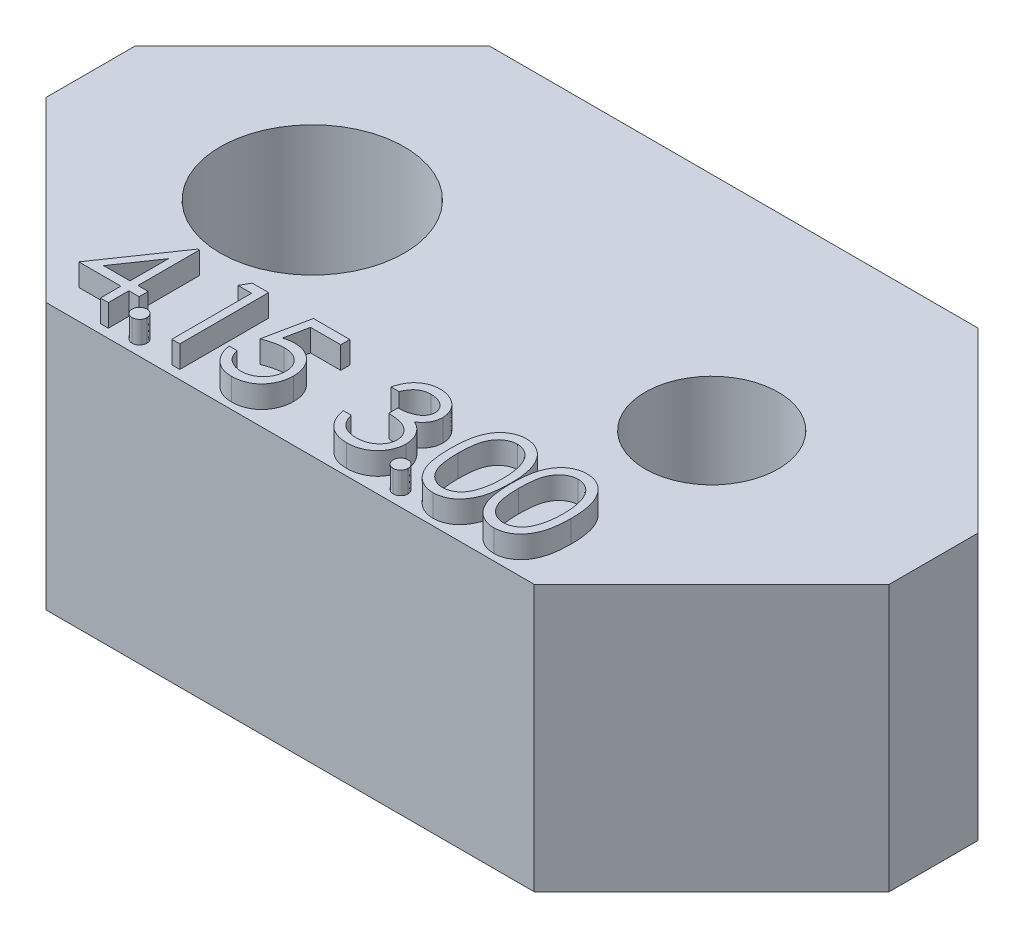
from build123d import *

# Parameters (mm, degrees)
SKETCH_1_R      = 2.075
SKETCH_1_R_2    = 1.5
EXTRUDE_1_DEPTH = 6
SKETCH_1_3_R    = 2.075
SKETCH_1_3_R_2  = 1.5
EXTRUDE_2_DEPTH = 2
EXTRUDE_3_DEPTH = 0.5


with BuildPart() as part:
    # Эскиз1 → Бобышка-Вытянуть1 (new body)
    with BuildSketch(Plane(origin=(0, 0, 0), x_dir=(1, 0, 0), z_dir=(0, 1, 0))):
        Polygon((9.5, 1), (5.5, 5), (-5.5, 5), (-9.5, 1), (-9.5, -1), (-5.5, -5), (5.5, -5), (9.5, -1), align=None)
        with Locations((-4.5, 0)):
            Circle(SKETCH_1_R, mode=Mode.SUBTRACT)
        with Locations((4.5, 0)):
            Circle(SKETCH_1_R_2, mode=Mode.SUBTRACT)
    extrude(amount=EXTRUDE_1_DEPTH)

    # Эскиз1<3> → Бобышка-Вытянуть2 (add)
    with BuildSketch(Plane(origin=(0, 0, 0), x_dir=(1, 0, 0), z_dir=(0, 1, 0))):
        with Locations((-4.5, 0)):
            Circle(SKETCH_1_3_R)
        with Locations((4.5, 0)):
            Circle(SKETCH_1_3_R_2)
    extrude(amount=EXTRUDE_2_DEPTH)

    # Эскиз3 → Бобышка-Вытянуть3 (add)
    # profile 1 of 8: a face of its own
    with BuildSketch(Plane(origin=(0, 6, 0), x_dir=(1, 0, 0), z_dir=(0, 1, 0))):
        Polygon((-4.331330128, -2.748717949), (-4.294871795, -2.748717949), (-4.294871795, -4.133333333), (-4.064102564, -4.133333333), (-4.064102564, -4.338461538), (-4.294871795, -4.338461538), (-4.294871795, -4.8), (-4.474358974, -4.8), (-4.474358974, -4.338461538), (-5.423076923, -4.338461538), align=None)
        Polygon((-4.474358974, -4.133333333), (-4.474358974, -3.26474359), (-5.070512821, -4.133333333), align=None, mode=Mode.SUBTRACT)
    # profile 2 of 8: a face of its own
    with BuildSketch(Plane(origin=(0, 6, 0), x_dir=(1, 0, 0), z_dir=(0, 1, 0))):
        with BuildLine():
            add(Edge.make_bspline(
                [(-3.733333333, -4.492307692), (-3.722196069, -4.492969502), (-3.700362765, -4.494266902), (-3.668797549, -4.503167858), (-3.640229172, -4.518972807), (-3.614782175, -4.540037252), (-3.593807045, -4.565577631), (-3.577438844, -4.59391815), (-3.568615424, -4.625747632), (-3.567327474, -4.647707446), (-3.566666667, -4.658974359)],
                knots=[0, 0, 0, 0, 1.020151414, 1.999887582, 2.974338812, 3.990962822, 5.007586832, 5.987933904, 6.967670073, 8, 8, 8, 8], degree=3))
            add(Edge.make_bspline(
                [(-3.566666667, -4.658974359), (-3.567349867, -4.669970547), (-3.568697128, -4.69165487), (-3.577418619, -4.723244277), (-3.59393179, -4.751602508), (-3.6146375, -4.777489444), (-3.640235462, -4.798598513), (-3.668865089, -4.814268996), (-3.700288665, -4.82380727), (-3.722183707, -4.825022297), (-3.733333333, -4.825641026)],
                knots=[0, 0, 0, 0, 1.009421747, 1.99056486, 2.972319754, 3.999869655, 5.017953583, 5.993804169, 6.978383603, 8, 8, 8, 8], degree=3))
            add(Edge.make_bspline(
                [(-3.733333333, -4.825641026), (-3.744490994, -4.825044684), (-3.766273669, -4.82388047), (-3.797579952, -4.814073152), (-3.826383934, -4.798745461), (-3.851976912, -4.777450084), (-3.872856039, -4.751735716), (-3.888641972, -4.723048975), (-3.898122057, -4.691745297), (-3.899368841, -4.669988358), (-3.9, -4.658974359)],
                knots=[0, 0, 0, 0, 1.022052826, 1.995314843, 2.982371812, 4.00089066, 5.028879526, 6.005146991, 6.990147033, 8, 8, 8, 8], degree=3))
            add(Edge.make_bspline(
                [(-3.9, -4.658974359), (-3.899393086, -4.647688999), (-3.898208161, -4.625655719), (-3.88862207, -4.594113372), (-3.87297852, -4.565445692), (-3.85183258, -4.540076218), (-3.826390125, -4.518826331), (-3.797649437, -4.503360735), (-3.766198271, -4.494194785), (-3.744478306, -4.492947633), (-3.733333333, -4.492307692)],
                knots=[0, 0, 0, 0, 1.032775665, 2.016367738, 2.991239715, 4.008302682, 5.025365648, 6.011011707, 6.979408107, 8, 8, 8, 8], degree=3))
        make_face()
    # profile 3 of 8: a face of its own
    with BuildSketch(Plane(origin=(0, 6, 0), x_dir=(1, 0, 0), z_dir=(0, 1, 0))):
        Polygon((-3.054407051, -2.8), (-2.684615385, -2.8), (-2.684615385, -4.8), (-2.864102564, -4.8), (-2.864102564, -3.005128205), (-3.171794872, -3.005128205), align=None)
    # profile 4 of 8: a face of its own
    with BuildSketch(Plane(origin=(0, 6, 0), x_dir=(1, 0, 0), z_dir=(0, 1, 0))):
        with BuildLine():
            Line((-0.853846154, -2.8), (-0.853846154, -3.005128205))
            Line((-0.853846154, -3.005128205), (-1.534134615, -3.005128205))
            Line((-1.534134615, -3.005128205), (-1.641907051, -3.531169872))
            add(Edge.make_bspline(
                [(-1.641907051, -3.531169872), (-1.620732266, -3.525324002), (-1.579709468, -3.513998554), (-1.519160976, -3.501423828), (-1.461679717, -3.493843575), (-1.424379506, -3.49280854), (-1.406330128, -3.492307692)],
                knots=[0, 0, 0, 0, 1.100273476, 2.13160584, 3.095893838, 4, 4, 4, 4], degree=3))
            add(Edge.make_bspline(
                [(-1.406330128, -3.492307692), (-1.383996563, -3.492791084), (-1.340083193, -3.493741553), (-1.275832366, -3.502868324), (-1.214499284, -3.51723399), (-1.156212215, -3.537302859), (-1.100863329, -3.562965564), (-1.048961866, -3.595022673), (-0.999728772, -3.632470291), (-0.95404729, -3.675524583), (-0.912604828, -3.722908364), (-0.87616712, -3.773855719), (-0.845217068, -3.827871526), (-0.820325208, -3.885471874), (-0.800448446, -3.946019962), (-0.787218735, -4.010152866), (-0.778409187, -4.077266077), (-0.777424966, -4.123154403), (-0.776923077, -4.146554487)],
                knots=[0, 0, 0, 0, 1.052922333, 2.070308379, 3.05430497, 4.020497103, 4.973039431, 5.925935799, 6.892292201, 7.88610001, 8.88166317, 9.857072816, 10.836096531, 11.812156883, 12.81219415, 13.836441305, 14.89672472, 16, 16, 16, 16], degree=3))
            add(Edge.make_bspline(
                [(-0.776923077, -4.146554487), (-0.77730312, -4.162852899), (-0.77805807, -4.195229463), (-0.781897263, -4.243311864), (-0.789289101, -4.29037634), (-0.799213514, -4.336429135), (-0.812094896, -4.381383062), (-0.827688641, -4.425366792), (-0.846772086, -4.468106567), (-0.8677043, -4.510006793), (-0.891273716, -4.550120226), (-0.917432863, -4.587633932), (-0.945070287, -4.623110665), (-0.974808221, -4.656169941), (-1.006923076, -4.686594522), (-1.041025914, -4.714564969), (-1.07684461, -4.740554301), (-1.11493332, -4.763507555), (-1.15444331, -4.784629244), (-1.195945149, -4.80195698), (-1.238494121, -4.81744871), (-1.282702621, -4.829797012), (-1.328470514, -4.839472757), (-1.375873243, -4.846044529), (-1.424662197, -4.850831064), (-1.457733633, -4.851130697), (-1.474439103, -4.851282051)],
                knots=[0, 0, 0, 0, 1.056347294, 2.098418968, 3.122841568, 4.141288669, 5.149314143, 6.15115421, 7.162517403, 8.180376062, 9.185164535, 10.17417709, 11.141909838, 12.097768115, 13.052685741, 14.0056014, 14.954263652, 15.917497458, 16.885230207, 17.854509472, 18.828990115, 19.81800267, 20.826176721, 21.857883937, 22.917946725, 24, 24, 24, 24], degree=3))
            add(Edge.make_bspline(
                [(-1.474439103, -4.851282051), (-1.494367206, -4.850887287), (-1.533573395, -4.850110634), (-1.591013719, -4.841985785), (-1.646279208, -4.830349262), (-1.69892498, -4.812842822), (-1.749422845, -4.790907225), (-1.797092969, -4.763183698), (-1.843153413, -4.731767068), (-1.885731719, -4.69469258), (-1.925249499, -4.654169333), (-1.960624647, -4.610193538), (-1.992129548, -4.563491), (-2.019259689, -4.513834912), (-2.042401415, -4.461355751), (-2.060581408, -4.405856894), (-2.075254754, -4.34762832), (-2.081462423, -4.3075406), (-2.084615385, -4.287179487)],
                knots=[0, 0, 0, 0, 1.0467383, 2.05933395, 3.04377827, 4.011590433, 4.970194871, 5.932262533, 6.905835911, 7.896367577, 8.894135286, 9.877477877, 10.858688626, 11.851381753, 12.8477658, 13.868841284, 14.917554742, 16, 16, 16, 16], degree=3))
            Line((-2.084615385, -4.287179487), (-1.905128205, -4.287179487))
            add(Edge.make_bspline(
                [(-1.905128205, -4.287179487), (-1.900711887, -4.306251746), (-1.892223477, -4.342909686), (-1.873591621, -4.394413309), (-1.850811121, -4.440310009), (-1.823722921, -4.481206913), (-1.791408618, -4.516869197), (-1.754534659, -4.548650376), (-1.713193103, -4.577321878), (-1.667254114, -4.601220602), (-1.618789498, -4.621602747), (-1.568065378, -4.635175144), (-1.516462894, -4.644718511), (-1.481560968, -4.645673803), (-1.464022436, -4.646153846)],
                knots=[0, 0, 0, 0, 1.136247022, 2.183929868, 3.172523383, 4.106158343, 5.02341133, 5.958108904, 6.928429099, 7.938127109, 8.96079061, 9.975095812, 10.982467395, 12, 12, 12, 12], degree=3))
            add(Edge.make_bspline(
                [(-1.464022436, -4.646153846), (-1.446903325, -4.64568483), (-1.413195655, -4.644761334), (-1.363589148, -4.637653327), (-1.315696077, -4.626706143), (-1.269989016, -4.610323369), (-1.225668137, -4.590412102), (-1.183854553, -4.56486063), (-1.143338624, -4.535454905), (-1.10537969, -4.501765402), (-1.070614291, -4.464639862), (-1.039896507, -4.424938494), (-1.014309699, -4.382586011), (-0.992747352, -4.338315638), (-0.976374038, -4.291642176), (-0.964693477, -4.242784362), (-0.957834586, -4.191621516), (-0.956891055, -4.156724768), (-0.956410256, -4.138942308)],
                knots=[0, 0, 0, 0, 1.027316725, 2.022795036, 3.002884548, 3.971462791, 4.93288096, 5.914575861, 6.907176829, 7.935150275, 8.956128384, 9.956726525, 10.942570165, 11.921478529, 12.907843606, 13.90538589, 14.932640048, 16, 16, 16, 16], degree=3))
            add(Edge.make_bspline(
                [(-0.956410256, -4.138942308), (-0.95678653, -4.122899021), (-0.957523033, -4.09149657), (-0.963540502, -4.045554166), (-0.974007343, -4.002083857), (-0.988535275, -3.960875723), (-1.006980708, -3.921890899), (-1.029521458, -3.88508915), (-1.056580542, -3.850955531), (-1.087490193, -3.819474072), (-1.12135193, -3.790419858), (-1.158748355, -3.765651808), (-1.198896884, -3.744815284), (-1.241313798, -3.72683357), (-1.287008026, -3.713918859), (-1.335074673, -3.704222924), (-1.386032792, -3.698614146), (-1.420873185, -3.697835924), (-1.438782051, -3.697435897)],
                knots=[0, 0, 0, 0, 1.045622112, 2.046656509, 3.013763289, 3.955457236, 4.890082067, 5.820317437, 6.762574623, 7.722996705, 8.69280354, 9.665887285, 10.63943826, 11.638615906, 12.663482002, 13.728887084, 14.832589034, 16, 16, 16, 16], degree=3))
            add(Edge.make_bspline(
                [(-1.438782051, -3.697435897), (-1.454284296, -3.697767664), (-1.486292499, -3.698452677), (-1.535391257, -3.70349639), (-1.586986528, -3.711633129), (-1.640880525, -3.722825271), (-1.697235101, -3.7374716), (-1.75593133, -3.755022744), (-1.817092625, -3.776006743), (-1.858302754, -3.791853722), (-1.879487179, -3.8)],
                knots=[0, 0, 0, 0, 0.817624296, 1.688186739, 2.600797293, 3.572016777, 4.590301741, 5.671205678, 6.80286297, 8, 8, 8, 8], degree=3))
            Line((-1.879487179, -3.8), (-1.674358974, -2.8))
            Line((-1.674358974, -2.8), (-0.853846154, -2.8))
        make_face()
    # profile 5 of 8: a face of its own
    with BuildSketch(Plane(origin=(0, 6, 0), x_dir=(1, 0, 0), z_dir=(0, 1, 0))):
        with BuildLine():
            Line((0.715384615, -3.261538462), (0.535897436, -3.261538462))
            add(Edge.make_bspline(
                [(0.535897436, -3.261538462), (0.540760036, -3.241405614), (0.550266022, -3.202047542), (0.570093207, -3.145814822), (0.591692782, -3.092601381), (0.617629413, -3.043403625), (0.645920129, -2.997232823), (0.678333113, -2.955136181), (0.713372955, -2.916043058), (0.752130069, -2.881349779), (0.792775018, -2.849933934), (0.835880515, -2.823148187), (0.880579311, -2.800105814), (0.927181102, -2.781122824), (0.975824628, -2.766822525), (1.026070127, -2.756447207), (1.07804927, -2.749709428), (1.113333608, -2.749051849), (1.13125, -2.748717949)],
                knots=[0, 0, 0, 0, 1.162005537, 2.271625781, 3.343758855, 4.383309926, 5.390229558, 6.379919256, 7.361854164, 8.333198761, 9.295911338, 10.242430842, 11.177959212, 12.116337295, 13.062827104, 14.020064771, 14.994644689, 16, 16, 16, 16], degree=3))
            add(Edge.make_bspline(
                [(1.13125, -2.748717949), (1.157354424, -2.74950608), (1.208993859, -2.751065152), (1.284858457, -2.765301973), (1.358016639, -2.78783062), (1.427667638, -2.818958464), (1.492363885, -2.857351214), (1.549927421, -2.90304535), (1.599577998, -2.955159236), (1.641231928, -3.012720702), (1.673846214, -3.074238136), (1.69789557, -3.137552511), (1.71253653, -3.202513638), (1.714433991, -3.24637494), (1.715384615, -3.268349359)],
                knots=[0, 0, 0, 0, 1.083050992, 2.142477498, 3.193116406, 4.255571735, 5.30263384, 6.308962982, 7.297363603, 8.282367274, 9.249857812, 10.179914175, 11.08814088, 12, 12, 12, 12], degree=3))
            add(Edge.make_bspline(
                [(1.715384615, -3.268349359), (1.714719706, -3.289496099), (1.713418582, -3.330876987), (1.70237075, -3.391289271), (1.6837786, -3.448227328), (1.65802445, -3.50193085), (1.624686421, -3.55205933), (1.584302023, -3.598725553), (1.536586216, -3.6421365), (1.500426823, -3.667004771), (1.481810897, -3.679807692)],
                knots=[0, 0, 0, 0, 1.024540389, 2.004866551, 2.965041327, 3.920577974, 4.882998113, 5.874504559, 6.905732034, 8, 8, 8, 8], degree=3))
            add(Edge.make_bspline(
                [(1.481810897, -3.679807692), (1.503086186, -3.690080933), (1.545238685, -3.710435195), (1.602696131, -3.75035277), (1.654854917, -3.796442112), (1.683942756, -3.832409342), (1.698557692, -3.850480769)],
                knots=[0, 0, 0, 0, 1.015518401, 2.012035669, 3.001164323, 4, 4, 4, 4], degree=3))
            add(Edge.make_bspline(
                [(1.698557692, -3.850480769), (1.708181317, -3.863656627), (1.727270971, -3.88979258), (1.750834134, -3.931813394), (1.77221077, -3.97429996), (1.788868038, -4.018391049), (1.801767391, -4.063575628), (1.810987981, -4.109931283), (1.816716061, -4.157495867), (1.817536377, -4.189674427), (1.817948718, -4.205849359)],
                knots=[0, 0, 0, 0, 1.025084078, 2.033381695, 3.024893161, 4.013698104, 4.991890475, 5.976764909, 6.982997093, 8, 8, 8, 8], degree=3))
            add(Edge.make_bspline(
                [(1.817948718, -4.205849359), (1.816923282, -4.233854914), (1.814877235, -4.289734229), (1.796589192, -4.372291213), (1.768238769, -4.4529915), (1.727977663, -4.530177123), (1.678910515, -4.602394483), (1.620534901, -4.667009517), (1.553514096, -4.722551576), (1.478768011, -4.768957421), (1.397786795, -4.806053377), (1.311172171, -4.831800487), (1.22017214, -4.848569629), (1.15776797, -4.85036784), (1.126041667, -4.851282051)],
                knots=[0, 0, 0, 0, 0.955779014, 1.907060117, 2.875433937, 3.871313158, 4.872415639, 5.851225146, 6.836215519, 7.83643374, 8.849228613, 9.86973379, 10.916971861, 12, 12, 12, 12], degree=3))
            add(Edge.make_bspline(
                [(1.126041667, -4.851282051), (1.104659209, -4.850785929), (1.062585664, -4.849809727), (1.000732236, -4.843136241), (0.941691265, -4.830947666), (0.885382923, -4.814545777), (0.831757188, -4.793750496), (0.7809777, -4.767854097), (0.732732046, -4.737390382), (0.687475503, -4.70199976), (0.645213464, -4.662410423), (0.60706905, -4.61791956), (0.572406311, -4.569349615), (0.542153375, -4.51613644), (0.514932259, -4.458967722), (0.492543141, -4.397111437), (0.472837102, -4.331120567), (0.463675122, -4.285133287), (0.458974359, -4.261538462)],
                knots=[0, 0, 0, 0, 1.048658725, 2.063410685, 3.046034179, 4.001477787, 4.936774919, 5.862367409, 6.792675028, 7.730719943, 8.675894397, 9.627829632, 10.600096036, 11.597688215, 12.626045268, 13.701542398, 14.82072376, 16, 16, 16, 16], degree=3))
            Line((0.458974359, -4.261538462), (0.638461538, -4.261538462))
            add(Edge.make_bspline(
                [(0.638461538, -4.261538462), (0.643137705, -4.276937898), (0.652233255, -4.306891139), (0.667715711, -4.349999885), (0.685354724, -4.389518772), (0.704277329, -4.425737699), (0.724150726, -4.459013358), (0.746387826, -4.488465854), (0.769341624, -4.515388827), (0.786644111, -4.530557177), (0.795112179, -4.537980769)],
                knots=[0, 0, 0, 0, 1.198163088, 2.33053128, 3.407730985, 4.417276592, 5.372219308, 6.28897303, 7.162600585, 8, 8, 8, 8], degree=3))
            add(Edge.make_bspline(
                [(0.795112179, -4.537980769), (0.806310223, -4.546614103), (0.828671745, -4.563854121), (0.865110734, -4.585855052), (0.903433526, -4.604918495), (0.944470483, -4.619480607), (0.987336066, -4.631810698), (1.032723132, -4.639879566), (1.080231256, -4.645415664), (1.112669978, -4.645904197), (1.129246795, -4.646153846)],
                knots=[0, 0, 0, 0, 0.946170439, 1.889420265, 2.845303464, 3.807233317, 4.801018734, 5.828864929, 6.890507805, 8, 8, 8, 8], degree=3))
            add(Edge.make_bspline(
                [(1.129246795, -4.646153846), (1.147963082, -4.6458019), (1.184561166, -4.645113701), (1.237963943, -4.638784725), (1.288768199, -4.629567346), (1.33640987, -4.615331356), (1.381513017, -4.597742298), (1.423445389, -4.575657495), (1.462757449, -4.549746225), (1.498945681, -4.520295278), (1.531485971, -4.488054423), (1.560137121, -4.454332668), (1.584494071, -4.419272194), (1.60414183, -4.382678982), (1.61965643, -4.344704566), (1.630218259, -4.305242378), (1.637561982, -4.264615368), (1.638160046, -4.236998815), (1.638461538, -4.223076923)],
                knots=[0, 0, 0, 0, 1.217147791, 2.380027433, 3.494444702, 4.572153297, 5.609568379, 6.639424714, 7.649109417, 8.668170816, 9.669597737, 10.625200337, 11.543417969, 12.441394052, 13.322311151, 14.205496177, 15.095365482, 16, 16, 16, 16], degree=3))
            add(Edge.make_bspline(
                [(1.638461538, -4.223076923), (1.63758708, -4.204441872), (1.635842516, -4.167264496), (1.622523327, -4.112568739), (1.600615405, -4.059869647), (1.569945398, -4.010066338), (1.532610696, -3.96390868), (1.488973607, -3.922724976), (1.438671762, -3.888742067), (1.392374694, -3.865262834), (1.351366033, -3.849241648), (1.316271528, -3.83857024), (1.27698204, -3.829533866), (1.233972698, -3.821126853), (1.186919431, -3.813971797), (1.135873467, -3.808005045), (1.08082446, -3.803230736), (1.042715222, -3.801098682), (1.023076923, -3.8)],
                knots=[0, 0, 0, 0, 1.07054697, 2.135767047, 3.216561865, 4.33974944, 5.486079747, 6.621378074, 7.775625952, 8.963672916, 9.598146892, 10.304877434, 11.070270905, 11.915000392, 12.823868403, 13.805723172, 14.86925407, 16, 16, 16, 16], degree=3))
            Line((1.023076923, -3.8), (1.023076923, -3.594871795))
            add(Edge.make_bspline(
                [(1.023076923, -3.594871795), (1.047820446, -3.594451907), (1.09628693, -3.59362945), (1.167083676, -3.583682015), (1.234782711, -3.569921656), (1.297883707, -3.548844404), (1.355397257, -3.524364234), (1.405294173, -3.495877257), (1.4468754, -3.464211686), (1.479938869, -3.428878767), (1.504812714, -3.390984454), (1.522999455, -3.351489221), (1.533742499, -3.3100469), (1.535176594, -3.281764233), (1.535897436, -3.267548077)],
                knots=[0, 0, 0, 0, 1.321986639, 2.589447074, 3.816329219, 5.01088745, 6.139805852, 7.153945165, 8.075214402, 8.924034688, 9.728124013, 10.488707548, 11.240355623, 12, 12, 12, 12], degree=3))
            add(Edge.make_bspline(
                [(1.535897436, -3.267548077), (1.53566063, -3.257103651), (1.535189515, -3.236324961), (1.529248213, -3.205967779), (1.52032019, -3.176538667), (1.508046059, -3.148162776), (1.491617374, -3.121036905), (1.47195681, -3.094929791), (1.448546467, -3.069990489), (1.421720497, -3.046744592), (1.392913752, -3.024590742), (1.361342452, -3.00578295), (1.327958523, -2.989700057), (1.292725006, -2.976437484), (1.25552756, -2.966460748), (1.216540956, -2.95929741), (1.175690851, -2.954818751), (1.14782129, -2.954173941), (1.133653846, -2.953846154)],
                knots=[0, 0, 0, 0, 0.884392785, 1.759457502, 2.611959086, 3.489218968, 4.37281399, 5.2945488, 6.255912374, 7.266815255, 8.301784654, 9.332968512, 10.37626691, 11.440494194, 12.520033166, 13.637162961, 14.798855837, 16, 16, 16, 16], degree=3))
            add(Edge.make_bspline(
                [(1.133653846, -2.953846154), (1.110881464, -2.954641218), (1.066401707, -2.956194163), (1.002278897, -2.969795885), (0.942667849, -2.991497647), (0.897102897, -3.017402229), (0.863455711, -3.042973906), (0.839411747, -3.065306698), (0.815800026, -3.090125454), (0.794173925, -3.118958812), (0.772303081, -3.14985412), (0.752391903, -3.184381938), (0.733043508, -3.221641592), (0.721384908, -3.247981955), (0.715384615, -3.261538462)],
                knots=[0, 0, 0, 0, 1.472543308, 2.876219568, 4.221790263, 5.565193594, 6.249813518, 6.953379497, 7.687249741, 8.463570142, 9.283606569, 10.136032583, 11.040678096, 12, 12, 12, 12], degree=3))
        make_face()
    # profile 6 of 8: a face of its own
    with BuildSketch(Plane(origin=(0, 6, 0), x_dir=(1, 0, 0), z_dir=(0, 1, 0))):
        with BuildLine():
            add(Edge.make_bspline(
                [(2.148717949, -4.492307692), (2.159855213, -4.492969502), (2.181688517, -4.494266902), (2.213253733, -4.503167858), (2.24182211, -4.518972807), (2.267269107, -4.540037252), (2.288244237, -4.565577631), (2.304612438, -4.59391815), (2.313435858, -4.625747632), (2.314723808, -4.647707446), (2.315384615, -4.658974359)],
                knots=[0, 0, 0, 0, 1.020151414, 1.999887582, 2.974338812, 3.990962822, 5.007586832, 5.987933904, 6.967670073, 8, 8, 8, 8], degree=3))
            add(Edge.make_bspline(
                [(2.315384615, -4.658974359), (2.314701415, -4.669970547), (2.313354154, -4.69165487), (2.304632663, -4.723244277), (2.288119492, -4.751602508), (2.267413782, -4.777489444), (2.24181582, -4.798598513), (2.213186193, -4.814268996), (2.181762617, -4.82380727), (2.159867575, -4.825022297), (2.148717949, -4.825641026)],
                knots=[0, 0, 0, 0, 1.009421747, 1.99056486, 2.972319754, 3.999869655, 5.017953583, 5.993804169, 6.978383603, 8, 8, 8, 8], degree=3))
            add(Edge.make_bspline(
                [(2.148717949, -4.825641026), (2.137560288, -4.825044684), (2.115777613, -4.82388047), (2.08447133, -4.814073152), (2.055667348, -4.798745461), (2.03007437, -4.777450084), (2.009195243, -4.751735716), (1.99340931, -4.723048975), (1.983929225, -4.691745297), (1.982682441, -4.669988358), (1.982051282, -4.658974359)],
                knots=[0, 0, 0, 0, 1.022052826, 1.995314843, 2.982371812, 4.00089066, 5.028879526, 6.005146991, 6.990147033, 8, 8, 8, 8], degree=3))
            add(Edge.make_bspline(
                [(1.982051282, -4.658974359), (1.982658196, -4.647688999), (1.983843121, -4.625655719), (1.993429212, -4.594113372), (2.009072762, -4.565445692), (2.030218702, -4.540076218), (2.055661157, -4.518826331), (2.084401845, -4.503360735), (2.115853011, -4.494194785), (2.137572976, -4.492947633), (2.148717949, -4.492307692)],
                knots=[0, 0, 0, 0, 1.032775665, 2.016367738, 2.991239715, 4.008302682, 5.025365648, 6.011011707, 6.979408107, 8, 8, 8, 8], degree=3))
        make_face()
    # profile 7 of 8: a face of its own
    with BuildSketch(Plane(origin=(0, 6, 0), x_dir=(1, 0, 0), z_dir=(0, 1, 0))):
        with BuildLine():
            add(Edge.make_bspline(
                [(2.402564103, -3.800801282), (2.402751542, -3.768745632), (2.403115644, -3.706477069), (2.407166171, -3.615742988), (2.413894938, -3.530622823), (2.423116294, -3.4511125), (2.434337997, -3.377191491), (2.449318275, -3.309057344), (2.466354162, -3.246394712), (2.486098417, -3.188999256), (2.508377153, -3.136097711), (2.532625302, -3.086711882), (2.559805185, -3.040916492), (2.588363421, -2.997980612), (2.619456033, -2.958607072), (2.652198199, -2.922239836), (2.687867843, -2.889719407), (2.725252419, -2.860092949), (2.764690398, -2.834121822), (2.805057636, -2.811245972), (2.846631982, -2.79170319), (2.889526944, -2.776337227), (2.933356977, -2.763645314), (2.978275301, -2.754965916), (3.02435608, -2.749504825), (3.055459757, -2.748982729), (3.071233974, -2.748717949)],
                knots=[0, 0, 0, 0, 1.646270934, 3.197905019, 4.663502075, 6.030701355, 7.308322542, 8.50163776, 9.611534131, 10.641858119, 11.616356847, 12.558055219, 13.465016945, 14.349605745, 15.204443733, 16.039544428, 16.859896111, 17.680448484, 18.487036065, 19.28249412, 20.06191084, 20.843045899, 21.620316918, 22.403196591, 23.190181807, 24, 24, 24, 24], degree=3))
            add(Edge.make_bspline(
                [(3.071233974, -2.748717949), (3.087139962, -2.7489967), (3.118771967, -2.749551049), (3.165537896, -2.754879016), (3.211223428, -2.763719658), (3.255633793, -2.776245929), (3.299133786, -2.791786316), (3.341383161, -2.811264669), (3.382644351, -2.833938307), (3.422261658, -2.860580523), (3.46067001, -2.890284681), (3.496925988, -2.923863349), (3.531032895, -2.960977474), (3.563418783, -3.001229968), (3.593164839, -3.045392873), (3.621492515, -3.092698079), (3.646847964, -3.143972859), (3.671267778, -3.198361697), (3.692346056, -3.257369502), (3.711355339, -3.320663651), (3.72671475, -3.388991758), (3.73950862, -3.461995327), (3.749419989, -3.53994246), (3.756638641, -3.622666069), (3.760451833, -3.710220578), (3.761169948, -3.770082206), (3.761538462, -3.800801282)],
                knots=[0, 0, 0, 0, 0.810914788, 1.612654377, 2.396697861, 3.181598691, 3.963628158, 4.749916497, 5.551656086, 6.361998678, 7.18212741, 8.025565596, 8.878627764, 9.750805457, 10.657531673, 11.591944965, 12.560506719, 13.57287815, 14.630710178, 15.753379473, 16.941251878, 18.199788006, 19.531962791, 20.947069417, 22.433333509, 24, 24, 24, 24], degree=3))
            add(Edge.make_bspline(
                [(3.761538462, -3.800801282), (3.761166128, -3.831386372), (3.76044065, -3.890980173), (3.756681389, -3.978140731), (3.749276457, -4.060425327), (3.740013606, -4.138031305), (3.727184485, -4.210635659), (3.711410104, -4.27848963), (3.693895634, -4.341886242), (3.672275751, -4.400306134), (3.648612488, -4.454564262), (3.622866662, -4.505231204), (3.595283904, -4.552754799), (3.565233193, -4.596754655), (3.533202671, -4.637542459), (3.498506792, -4.674398243), (3.4621236, -4.708210056), (3.42360222, -4.7382967), (3.383367047, -4.764630874), (3.342247575, -4.788181646), (3.299514213, -4.807171757), (3.256135383, -4.823477495), (3.211490602, -4.835934896), (3.165635522, -4.844548528), (3.118803387, -4.850589584), (3.08714535, -4.85105043), (3.071233974, -4.851282051)],
                knots=[0, 0, 0, 0, 1.561518951, 3.042555995, 4.452378317, 5.7783523, 7.031515105, 8.214008947, 9.334062868, 10.386615937, 11.391082383, 12.354592575, 13.286541444, 14.194233754, 15.072674879, 15.931287219, 16.775624067, 17.606195743, 18.42308326, 19.229000347, 20.022332153, 20.807536673, 21.593273796, 22.3848459, 23.188221202, 24, 24, 24, 24], degree=3))
            add(Edge.make_bspline(
                [(3.071233974, -4.851282051), (3.055460195, -4.851015562), (3.024357381, -4.850490098), (2.978270281, -4.84505368), (2.933537456, -4.836313393), (2.889938168, -4.824075333), (2.847248731, -4.809095427), (2.806050852, -4.789579036), (2.765886462, -4.767102426), (2.726862715, -4.741505042), (2.689712909, -4.712178366), (2.654227992, -4.679741629), (2.621299409, -4.643385394), (2.590651355, -4.603683724), (2.561523304, -4.561001871), (2.534729377, -4.514757087), (2.509946032, -4.465132738), (2.487292608, -4.411808217), (2.467207658, -4.354005401), (2.44946611, -4.291063014), (2.43545802, -4.222425507), (2.42346776, -4.148644155), (2.413796684, -4.069401909), (2.407194213, -3.98465575), (2.403113461, -3.894458488), (2.402750564, -3.832590045), (2.402564103, -3.800801282)],
                knots=[0, 0, 0, 0, 0.810891512, 1.598919785, 2.382837074, 3.152667961, 3.926044502, 4.706494248, 5.493654104, 6.291793342, 7.103789334, 7.925228297, 8.761435821, 9.622817696, 10.50288917, 11.416980706, 12.369136599, 13.353924996, 14.394355917, 15.514179734, 16.714354668, 17.994756427, 19.357759367, 20.818452758, 22.365282078, 24, 24, 24, 24], degree=3))
        make_face()
        with BuildLine():
            add(Edge.make_bspline(
                [(2.582051282, -3.8), (2.582119538, -3.826713542), (2.582252008, -3.878559282), (2.585712694, -3.953898288), (2.590427112, -4.024167048), (2.596507854, -4.089454783), (2.60553811, -4.149540504), (2.615656274, -4.204837466), (2.627969468, -4.25505303), (2.64253805, -4.300531779), (2.65913182, -4.342045532), (2.677249456, -4.380674798), (2.696712726, -4.416875905), (2.718495098, -4.450323681), (2.742217991, -4.481127203), (2.767345568, -4.509831679), (2.794815616, -4.535429954), (2.832817755, -4.566131014), (2.882987169, -4.597856233), (2.946198857, -4.62548257), (3.011152258, -4.642843974), (3.055238687, -4.645051835), (3.07724359, -4.646153846)],
                knots=[0, 0, 0, 0, 1.459021318, 2.831673884, 4.118529203, 5.306027144, 6.411944654, 7.436330062, 8.375795394, 9.233974572, 10.042671642, 10.816086306, 11.563610507, 12.285937304, 12.993564865, 13.685989202, 14.367179055, 15.041617293, 16.353048772, 17.594441528, 18.799311195, 20, 20, 20, 20], degree=3))
            add(Edge.make_bspline(
                [(3.07724359, -4.646153846), (3.099390831, -4.645240829), (3.143639587, -4.643416678), (3.20828747, -4.6258174), (3.271047624, -4.599263377), (3.32023159, -4.567864803), (3.357650186, -4.5379629), (3.384459895, -4.512468816), (3.40906678, -4.483922606), (3.432405108, -4.453123008), (3.453810294, -4.419481588), (3.473274944, -4.383160117), (3.491036857, -4.344057729), (3.501156312, -4.316760736), (3.506330128, -4.302804487)],
                knots=[0, 0, 0, 0, 1.353760809, 2.704726607, 4.075137775, 5.516104923, 6.260822281, 7.007110065, 7.778089737, 8.566572457, 9.372053459, 10.217411131, 11.088608312, 12, 12, 12, 12], degree=3))
            add(Edge.make_bspline(
                [(3.506330128, -4.302804487), (3.51235971, -4.284958922), (3.524602346, -4.248724771), (3.540380503, -4.19251697), (3.552806445, -4.133543962), (3.563985512, -4.072158181), (3.571615829, -4.007906923), (3.577757437, -3.940988989), (3.581374972, -3.871353925), (3.581823401, -3.824042502), (3.582051282, -3.8)],
                knots=[0, 0, 0, 0, 0.884706709, 1.796334032, 2.740027952, 3.714592787, 4.726048262, 5.777819803, 6.87074269, 8, 8, 8, 8], degree=3))
            add(Edge.make_bspline(
                [(3.582051282, -3.8), (3.581736888, -3.775961387), (3.581121867, -3.728936722), (3.578771017, -3.66006919), (3.572700403, -3.594659041), (3.565958049, -3.532424485), (3.55601678, -3.473710026), (3.545298033, -3.418024137), (3.53089734, -3.366056695), (3.515514612, -3.316994077), (3.497908671, -3.271393703), (3.478528252, -3.229042967), (3.457830104, -3.18973741), (3.435348824, -3.153584872), (3.41135129, -3.120423419), (3.385204119, -3.090917937), (3.357944478, -3.064153955), (3.319763229, -3.033603915), (3.26977792, -3.002454375), (3.207580408, -2.973788227), (3.142854325, -2.957326345), (3.099098066, -2.955005381), (3.07724359, -2.953846154)],
                knots=[0, 0, 0, 0, 1.31362396, 2.569729283, 3.763502607, 4.902122613, 5.988968491, 7.01645872, 7.998833611, 8.933434873, 9.825090667, 10.667526885, 11.477055099, 12.250526234, 12.991942729, 13.710640831, 14.402115721, 15.076753259, 16.378508321, 17.609869233, 18.806226677, 20, 20, 20, 20], degree=3))
            add(Edge.make_bspline(
                [(3.07724359, -2.953846154), (3.055123251, -2.955006981), (3.010842277, -2.957330749), (2.945443446, -2.973726893), (2.882755245, -3.002305731), (2.832902116, -3.033707087), (2.794694238, -3.063614693), (2.767789842, -3.08954981), (2.742563458, -3.117919098), (2.719324772, -3.149005907), (2.697559467, -3.182414688), (2.677570317, -3.218408268), (2.659560415, -3.257169047), (2.64294068, -3.298664153), (2.628327658, -3.344138979), (2.616273965, -3.394292689), (2.605138506, -3.44941377), (2.597255495, -3.509824918), (2.590247635, -3.575129005), (2.585744007, -3.645573187), (2.582240431, -3.721038548), (2.582115595, -3.773152352), (2.582051282, -3.8)],
                knots=[0, 0, 0, 0, 1.207732386, 2.417664972, 3.655092373, 4.956220595, 5.625982001, 6.301752483, 6.994047911, 7.697131622, 8.419323945, 9.170223765, 9.943494443, 10.752040957, 11.610060368, 12.549350801, 13.567764191, 14.679664412, 15.874934091, 17.154273443, 18.533957287, 20, 20, 20, 20], degree=3))
        make_face(mode=Mode.SUBTRACT)
    # profile 8 of 8: a face of its own
    with BuildSketch(Plane(origin=(0, 6, 0), x_dir=(1, 0, 0), z_dir=(0, 1, 0))):
        with BuildLine():
            add(Edge.make_bspline(
                [(3.771794872, -3.800801282), (3.771982311, -3.768745632), (3.772346414, -3.706477069), (3.77639694, -3.615742988), (3.783125707, -3.530622823), (3.792347063, -3.4511125), (3.803568766, -3.377191491), (3.818549044, -3.309057344), (3.835584931, -3.246394712), (3.855329186, -3.188999256), (3.877607922, -3.136097711), (3.901856071, -3.086711882), (3.929035954, -3.040916492), (3.95759419, -2.997980612), (3.988686802, -2.958607072), (4.021428968, -2.922239836), (4.057098612, -2.889719407), (4.094483188, -2.860092949), (4.133921168, -2.834121822), (4.174288405, -2.811245972), (4.215862752, -2.79170319), (4.258757713, -2.776337227), (4.302587746, -2.763645314), (4.34750607, -2.754965916), (4.39358685, -2.749504825), (4.424690527, -2.748982729), (4.440464744, -2.748717949)],
                knots=[0, 0, 0, 0, 1.646270934, 3.197905019, 4.663502075, 6.030701355, 7.308322542, 8.50163776, 9.611534131, 10.641858119, 11.616356847, 12.558055219, 13.465016945, 14.349605745, 15.204443733, 16.039544428, 16.859896111, 17.680448484, 18.487036065, 19.28249412, 20.06191084, 20.843045899, 21.620316918, 22.403196591, 23.190181807, 24, 24, 24, 24], degree=3))
            add(Edge.make_bspline(
                [(4.440464744, -2.748717949), (4.456370731, -2.7489967), (4.488002736, -2.749551049), (4.534768665, -2.754879016), (4.580454197, -2.763719658), (4.624864562, -2.776245929), (4.668364555, -2.791786316), (4.710613931, -2.811264669), (4.75187512, -2.833938307), (4.791492427, -2.860580523), (4.829900779, -2.890284681), (4.866156758, -2.923863349), (4.900263664, -2.960977474), (4.932649553, -3.001229968), (4.962395608, -3.045392873), (4.990723284, -3.092698079), (5.016078733, -3.143972859), (5.040498547, -3.198361697), (5.061576825, -3.257369502), (5.080586108, -3.320663651), (5.095945519, -3.388991758), (5.108739389, -3.461995327), (5.118650758, -3.53994246), (5.125869411, -3.622666069), (5.129682602, -3.710220578), (5.130400717, -3.770082206), (5.130769231, -3.800801282)],
                knots=[0, 0, 0, 0, 0.810914788, 1.612654377, 2.396697861, 3.181598691, 3.963628158, 4.749916497, 5.551656086, 6.361998678, 7.18212741, 8.025565596, 8.878627764, 9.750805457, 10.657531673, 11.591944965, 12.560506719, 13.57287815, 14.630710178, 15.753379473, 16.941251878, 18.199788006, 19.531962791, 20.947069417, 22.433333509, 24, 24, 24, 24], degree=3))
            add(Edge.make_bspline(
                [(5.130769231, -3.800801282), (5.130396897, -3.831386372), (5.129671419, -3.890980173), (5.125912158, -3.978140731), (5.118507226, -4.060425327), (5.109244376, -4.138031305), (5.096415254, -4.210635659), (5.080640873, -4.27848963), (5.063126403, -4.341886242), (5.041506521, -4.400306134), (5.017843258, -4.454564262), (4.992097431, -4.505231204), (4.964514673, -4.552754799), (4.934463962, -4.596754655), (4.90243344, -4.637542459), (4.867737561, -4.674398243), (4.831354369, -4.708210056), (4.792832989, -4.7382967), (4.752597817, -4.764630874), (4.711478344, -4.788181646), (4.668744982, -4.807171757), (4.625366152, -4.823477495), (4.580721371, -4.835934896), (4.534866291, -4.844548528), (4.488034156, -4.850589584), (4.456376119, -4.85105043), (4.440464744, -4.851282051)],
                knots=[0, 0, 0, 0, 1.561518951, 3.042555995, 4.452378317, 5.7783523, 7.031515105, 8.214008947, 9.334062868, 10.386615937, 11.391082383, 12.354592575, 13.286541444, 14.194233754, 15.072674879, 15.931287219, 16.775624067, 17.606195743, 18.42308326, 19.229000347, 20.022332153, 20.807536673, 21.593273796, 22.3848459, 23.188221202, 24, 24, 24, 24], degree=3))
            add(Edge.make_bspline(
                [(4.440464744, -4.851282051), (4.424690964, -4.851015562), (4.39358815, -4.850490098), (4.34750105, -4.84505368), (4.302768225, -4.836313393), (4.259168937, -4.824075333), (4.2164795, -4.809095427), (4.175281622, -4.789579036), (4.135117231, -4.767102426), (4.096093485, -4.741505042), (4.058943678, -4.712178366), (4.023458761, -4.679741629), (3.990530179, -4.643385394), (3.959882124, -4.603683724), (3.930754074, -4.561001871), (3.903960146, -4.514757087), (3.879176801, -4.465132738), (3.856523378, -4.411808217), (3.836438427, -4.354005401), (3.81869688, -4.291063014), (3.80468879, -4.222425507), (3.792698529, -4.148644155), (3.783027453, -4.069401909), (3.776424982, -3.98465575), (3.77234423, -3.894458488), (3.771981333, -3.832590045), (3.771794872, -3.800801282)],
                knots=[0, 0, 0, 0, 0.810891512, 1.598919785, 2.382837074, 3.152667961, 3.926044502, 4.706494248, 5.493654104, 6.291793342, 7.103789334, 7.925228297, 8.761435821, 9.622817696, 10.50288917, 11.416980706, 12.369136599, 13.353924996, 14.394355917, 15.514179734, 16.714354668, 17.994756427, 19.357759367, 20.818452758, 22.365282078, 24, 24, 24, 24], degree=3))
        make_face()
        with BuildLine():
            add(Edge.make_bspline(
                [(3.951282051, -3.8), (3.951350307, -3.826713542), (3.951482777, -3.878559282), (3.954943463, -3.953898288), (3.959657882, -4.024167048), (3.965738623, -4.089454783), (3.974768879, -4.149540504), (3.984887044, -4.204837466), (3.997200238, -4.25505303), (4.011768819, -4.300531779), (4.028362589, -4.342045532), (4.046480225, -4.380674798), (4.065943496, -4.416875905), (4.087725867, -4.450323681), (4.111448761, -4.481127203), (4.136576337, -4.509831679), (4.164046385, -4.535429954), (4.202048524, -4.566131014), (4.252217938, -4.597856233), (4.315429627, -4.62548257), (4.380383027, -4.642843974), (4.424469456, -4.645051835), (4.446474359, -4.646153846)],
                knots=[0, 0, 0, 0, 1.459021318, 2.831673884, 4.118529203, 5.306027144, 6.411944654, 7.436330062, 8.375795394, 9.233974572, 10.042671642, 10.816086306, 11.563610507, 12.285937304, 12.993564865, 13.685989202, 14.367179055, 15.041617293, 16.353048772, 17.594441528, 18.799311195, 20, 20, 20, 20], degree=3))
            add(Edge.make_bspline(
                [(4.446474359, -4.646153846), (4.4686216, -4.645240829), (4.512870356, -4.643416678), (4.577518239, -4.6258174), (4.640278393, -4.599263377), (4.689462359, -4.567864803), (4.726880955, -4.5379629), (4.753690664, -4.512468816), (4.778297549, -4.483922606), (4.801635877, -4.453123008), (4.823041063, -4.419481588), (4.842505714, -4.383160117), (4.860267626, -4.344057729), (4.870387081, -4.316760736), (4.875560897, -4.302804487)],
                knots=[0, 0, 0, 0, 1.353760809, 2.704726607, 4.075137775, 5.516104923, 6.260822281, 7.007110065, 7.778089737, 8.566572457, 9.372053459, 10.217411131, 11.088608312, 12, 12, 12, 12], degree=3))
            add(Edge.make_bspline(
                [(4.875560897, -4.302804487), (4.881590479, -4.284958922), (4.893833116, -4.248724771), (4.909611272, -4.19251697), (4.922037215, -4.133543962), (4.933216281, -4.072158181), (4.940846598, -4.007906923), (4.946988206, -3.940988989), (4.950605741, -3.871353925), (4.951054171, -3.824042502), (4.951282051, -3.8)],
                knots=[0, 0, 0, 0, 0.884706709, 1.796334032, 2.740027952, 3.714592787, 4.726048262, 5.777819803, 6.87074269, 8, 8, 8, 8], degree=3))
            add(Edge.make_bspline(
                [(4.951282051, -3.8), (4.950967657, -3.775961387), (4.950352636, -3.728936722), (4.948001786, -3.66006919), (4.941931172, -3.594659041), (4.935188818, -3.532424485), (4.925247549, -3.473710026), (4.914528802, -3.418024137), (4.900128109, -3.366056695), (4.884745381, -3.316994077), (4.867139441, -3.271393703), (4.847759021, -3.229042967), (4.827060873, -3.18973741), (4.804579593, -3.153584872), (4.78058206, -3.120423419), (4.754434889, -3.090917937), (4.727175247, -3.064153955), (4.688993998, -3.033603915), (4.63900869, -3.002454375), (4.576811177, -2.973788227), (4.512085094, -2.957326345), (4.468328835, -2.955005381), (4.446474359, -2.953846154)],
                knots=[0, 0, 0, 0, 1.31362396, 2.569729283, 3.763502607, 4.902122613, 5.988968491, 7.01645872, 7.998833611, 8.933434873, 9.825090667, 10.667526885, 11.477055099, 12.250526234, 12.991942729, 13.710640831, 14.402115721, 15.076753259, 16.378508321, 17.609869233, 18.806226677, 20, 20, 20, 20], degree=3))
            add(Edge.make_bspline(
                [(4.446474359, -2.953846154), (4.424354021, -2.955006981), (4.380073046, -2.957330749), (4.314674215, -2.973726893), (4.251986014, -3.002305731), (4.202132885, -3.033707087), (4.163925007, -3.063614693), (4.137020611, -3.08954981), (4.111794227, -3.117919098), (4.088555541, -3.149005907), (4.066790237, -3.182414688), (4.046801087, -3.218408268), (4.028791184, -3.257169047), (4.012171449, -3.298664153), (3.997558427, -3.344138979), (3.985504734, -3.394292689), (3.974369275, -3.44941377), (3.966486264, -3.509824918), (3.959478404, -3.575129005), (3.954974776, -3.645573187), (3.951471201, -3.721038548), (3.951346364, -3.773152352), (3.951282051, -3.8)],
                knots=[0, 0, 0, 0, 1.207732386, 2.417664972, 3.655092373, 4.956220595, 5.625982001, 6.301752483, 6.994047911, 7.697131622, 8.419323945, 9.170223765, 9.943494443, 10.752040957, 11.610060368, 12.549350801, 13.567764191, 14.679664412, 15.874934091, 17.154273443, 18.533957287, 20, 20, 20, 20], degree=3))
        make_face(mode=Mode.SUBTRACT)
    extrude(amount=EXTRUDE_3_DEPTH)


solid = part.part
